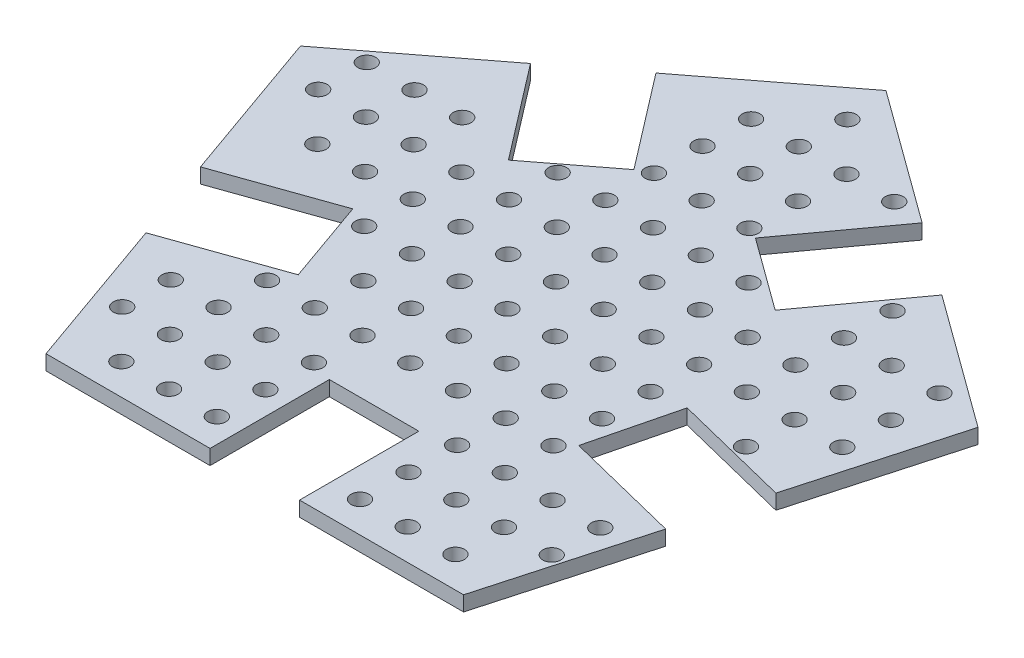
from build123d import *

# Parameters (mm, degrees)
SKETCH1_R           = 3
BOSS_EXTRUDE1_DEPTH = 5


with BuildPart() as part:
    # Sketch1 → Boss-Extrude1 (new body)
    with BuildSketch(Plane(origin=(0, 0, 0), x_dir=(1, 0, 0), z_dir=(0, 1, 0))):
        Polygon((33.8816744, 72.09863232), (-10.595420339, 104.452736288), (-54.231730978, 70.973303889), (-29.88305287, 39.237805242), (-53.684676855, 20.976296661), (-78.033354964, 52.711795308), (-121.669665603, 19.232362909), (-103.331670223, -32.62048586), (-65.620507482, -19.283761946), (-55.617964547, -47.567134002), (-93.329127288, -60.903857915), (-74.991131907, -112.756706684), (-19.991131907, -112.756706684), (-19.991131907, -72.756706684), (10.008868093, -72.756706684), (10.008868093, -112.756706684), (65.008868093, -112.756706684), (79.784278091, -59.778529484), (40.969230286, -50.114572533), (48.214362749, -21.014674397), (87.843592635, -30.881341921), (102.619002633, 22.096835279), (58.141907894, 54.450939247), (34.611650463, 22.103961255), (10.351416969, 39.751654328), align=None)
        with Locations((-105.788667233, 25.573221778)):
            Circle(SKETCH1_R, mode=Mode.SUBTRACT)
        with Locations((-89.788667233, 25.573221778)):
            Circle(SKETCH1_R, mode=Mode.SUBTRACT)
        with Locations((-73.788667233, 25.573221778)):
            Circle(SKETCH1_R, mode=Mode.SUBTRACT)
        with Locations((-41.788667233, 25.573221778)):
            Circle(SKETCH1_R, mode=Mode.SUBTRACT)
        with Locations((-25.788667233, 25.573221778)):
            Circle(SKETCH1_R, mode=Mode.SUBTRACT)
        with Locations((-9.788667233, 25.573221778)):
            Circle(SKETCH1_R, mode=Mode.SUBTRACT)
        with Locations((6.211332767, 25.573221778)):
            Circle(SKETCH1_R, mode=Mode.SUBTRACT)
        with Locations((22.211332767, 25.573221778)):
            Circle(SKETCH1_R, mode=Mode.SUBTRACT)
        with Locations((54.211332767, 25.573221778)):
            Circle(SKETCH1_R, mode=Mode.SUBTRACT)
        with Locations((70.211332767, 25.573221778)):
            Circle(SKETCH1_R, mode=Mode.SUBTRACT)
        with Locations((86.211332767, 25.573221778)):
            Circle(SKETCH1_R, mode=Mode.SUBTRACT)
        with Locations((-106.074287638, 9.575771325)):
            Circle(SKETCH1_R, mode=Mode.SUBTRACT)
        with Locations((-90.074287638, 9.575771325)):
            Circle(SKETCH1_R, mode=Mode.SUBTRACT)
        with Locations((-74.074287638, 9.575771325)):
            Circle(SKETCH1_R, mode=Mode.SUBTRACT)
        with Locations((-58.074287638, 9.575771325)):
            Circle(SKETCH1_R, mode=Mode.SUBTRACT)
        with Locations((-42.074287638, 9.575771325)):
            Circle(SKETCH1_R, mode=Mode.SUBTRACT)
        with Locations((-26.074287638, 9.575771325)):
            Circle(SKETCH1_R, mode=Mode.SUBTRACT)
        with Locations((-10.074287638, 9.575771325)):
            Circle(SKETCH1_R, mode=Mode.SUBTRACT)
        with Locations((5.925712362, 9.575771325)):
            Circle(SKETCH1_R, mode=Mode.SUBTRACT)
        with Locations((21.925712362, 9.575771325)):
            Circle(SKETCH1_R, mode=Mode.SUBTRACT)
        with Locations((37.925712362, 9.575771325)):
            Circle(SKETCH1_R, mode=Mode.SUBTRACT)
        with Locations((53.925712362, 9.575771325)):
            Circle(SKETCH1_R, mode=Mode.SUBTRACT)
        with Locations((69.925712362, 9.575771325)):
            Circle(SKETCH1_R, mode=Mode.SUBTRACT)
        with Locations((85.925712362, 9.575771325)):
            Circle(SKETCH1_R, mode=Mode.SUBTRACT)
        with Locations((-90.359908044, -6.421679127)):
            Circle(SKETCH1_R, mode=Mode.SUBTRACT)
        with Locations((-74.359908044, -6.421679127)):
            Circle(SKETCH1_R, mode=Mode.SUBTRACT)
        with Locations((-58.359908044, -6.421679127)):
            Circle(SKETCH1_R, mode=Mode.SUBTRACT)
        with Locations((-42.359908044, -6.421679127)):
            Circle(SKETCH1_R, mode=Mode.SUBTRACT)
        with Locations((-26.359908044, -6.421679127)):
            Circle(SKETCH1_R, mode=Mode.SUBTRACT)
        with Locations((-10.359908044, -6.421679127)):
            Circle(SKETCH1_R, mode=Mode.SUBTRACT)
        with Locations((5.640091956, -6.421679127)):
            Circle(SKETCH1_R, mode=Mode.SUBTRACT)
        with Locations((21.640091956, -6.421679127)):
            Circle(SKETCH1_R, mode=Mode.SUBTRACT)
        with Locations((37.640091956, -6.421679127)):
            Circle(SKETCH1_R, mode=Mode.SUBTRACT)
        with Locations((53.640091956, -6.421679127)):
            Circle(SKETCH1_R, mode=Mode.SUBTRACT)
        with Locations((69.640091956, -6.421679127)):
            Circle(SKETCH1_R, mode=Mode.SUBTRACT)
        with Locations((85.640091956, -6.421679127)):
            Circle(SKETCH1_R, mode=Mode.SUBTRACT)
        with Locations((-58.645528449, -22.41912958)):
            Circle(SKETCH1_R, mode=Mode.SUBTRACT)
        with Locations((-42.645528449, -22.41912958)):
            Circle(SKETCH1_R, mode=Mode.SUBTRACT)
        with Locations((-26.645528449, -22.41912958)):
            Circle(SKETCH1_R, mode=Mode.SUBTRACT)
        with Locations((-10.645528449, -22.41912958)):
            Circle(SKETCH1_R, mode=Mode.SUBTRACT)
        with Locations((5.354471551, -22.41912958)):
            Circle(SKETCH1_R, mode=Mode.SUBTRACT)
        with Locations((21.354471551, -22.41912958)):
            Circle(SKETCH1_R, mode=Mode.SUBTRACT)
        with Locations((37.354471551, -22.41912958)):
            Circle(SKETCH1_R, mode=Mode.SUBTRACT)
        with Locations((69.354471551, -22.41912958)):
            Circle(SKETCH1_R, mode=Mode.SUBTRACT)
        with Locations((-42.931148854, -38.416580032)):
            Circle(SKETCH1_R, mode=Mode.SUBTRACT)
        with Locations((-26.931148854, -38.416580032)):
            Circle(SKETCH1_R, mode=Mode.SUBTRACT)
        with Locations((-10.931148854, -38.416580032)):
            Circle(SKETCH1_R, mode=Mode.SUBTRACT)
        with Locations((5.068851146, -38.416580032)):
            Circle(SKETCH1_R, mode=Mode.SUBTRACT)
        with Locations((21.068851146, -38.416580032)):
            Circle(SKETCH1_R, mode=Mode.SUBTRACT)
        with Locations((37.068851146, -38.416580032)):
            Circle(SKETCH1_R, mode=Mode.SUBTRACT)
        with Locations((-59.216769259, -54.414030485)):
            Circle(SKETCH1_R, mode=Mode.SUBTRACT)
        with Locations((-43.216769259, -54.414030485)):
            Circle(SKETCH1_R, mode=Mode.SUBTRACT)
        with Locations((-27.216769259, -54.414030485)):
            Circle(SKETCH1_R, mode=Mode.SUBTRACT)
        with Locations((-11.216769259, -54.414030485)):
            Circle(SKETCH1_R, mode=Mode.SUBTRACT)
        with Locations((4.783230741, -54.414030485)):
            Circle(SKETCH1_R, mode=Mode.SUBTRACT)
        with Locations((20.783230741, -54.414030485)):
            Circle(SKETCH1_R, mode=Mode.SUBTRACT)
        with Locations((36.783230741, -54.414030485)):
            Circle(SKETCH1_R, mode=Mode.SUBTRACT)
        with Locations((-75.502389665, -70.411480938)):
            Circle(SKETCH1_R, mode=Mode.SUBTRACT)
        with Locations((-59.502389665, -70.411480938)):
            Circle(SKETCH1_R, mode=Mode.SUBTRACT)
        with Locations((-43.502389665, -70.411480938)):
            Circle(SKETCH1_R, mode=Mode.SUBTRACT)
        with Locations((-27.502389665, -70.411480938)):
            Circle(SKETCH1_R, mode=Mode.SUBTRACT)
        with Locations((20.497610335, -70.411480938)):
            Circle(SKETCH1_R, mode=Mode.SUBTRACT)
        with Locations((36.497610335, -70.411480938)):
            Circle(SKETCH1_R, mode=Mode.SUBTRACT)
        with Locations((52.497610335, -70.411480938)):
            Circle(SKETCH1_R, mode=Mode.SUBTRACT)
        with Locations((68.497610335, -70.411480938)):
            Circle(SKETCH1_R, mode=Mode.SUBTRACT)
        with Locations((-75.78801007, -86.40893139)):
            Circle(SKETCH1_R, mode=Mode.SUBTRACT)
        with Locations((-59.78801007, -86.40893139)):
            Circle(SKETCH1_R, mode=Mode.SUBTRACT)
        with Locations((-43.78801007, -86.40893139)):
            Circle(SKETCH1_R, mode=Mode.SUBTRACT)
        with Locations((-27.78801007, -86.40893139)):
            Circle(SKETCH1_R, mode=Mode.SUBTRACT)
        with Locations((20.21198993, -86.40893139)):
            Circle(SKETCH1_R, mode=Mode.SUBTRACT)
        with Locations((36.21198993, -86.40893139)):
            Circle(SKETCH1_R, mode=Mode.SUBTRACT)
        with Locations((52.21198993, -86.40893139)):
            Circle(SKETCH1_R, mode=Mode.SUBTRACT)
        with Locations((68.21198993, -86.40893139)):
            Circle(SKETCH1_R, mode=Mode.SUBTRACT)
        with Locations((-60.073630475, -102.406381843)):
            Circle(SKETCH1_R, mode=Mode.SUBTRACT)
        with Locations((-44.073630475, -102.406381843)):
            Circle(SKETCH1_R, mode=Mode.SUBTRACT)
        with Locations((-28.073630475, -102.406381843)):
            Circle(SKETCH1_R, mode=Mode.SUBTRACT)
        with Locations((19.926369525, -102.406381843)):
            Circle(SKETCH1_R, mode=Mode.SUBTRACT)
        with Locations((35.926369525, -102.406381843)):
            Circle(SKETCH1_R, mode=Mode.SUBTRACT)
        with Locations((51.926369525, -102.406381843)):
            Circle(SKETCH1_R, mode=Mode.SUBTRACT)
        with Locations((-25.217426422, 57.568122683)):
            Circle(SKETCH1_R, mode=Mode.SUBTRACT)
        with Locations((-9.217426422, 57.568122683)):
            Circle(SKETCH1_R, mode=Mode.SUBTRACT)
        with Locations((6.782573578, 57.568122683)):
            Circle(SKETCH1_R, mode=Mode.SUBTRACT)
        with Locations((-24.931806017, 73.565573136)):
            Circle(SKETCH1_R, mode=Mode.SUBTRACT)
        with Locations((-8.931806017, 73.565573136)):
            Circle(SKETCH1_R, mode=Mode.SUBTRACT)
        with Locations((7.068193983, 73.565573136)):
            Circle(SKETCH1_R, mode=Mode.SUBTRACT)
        with Locations((23.068193983, 73.565573136)):
            Circle(SKETCH1_R, mode=Mode.SUBTRACT)
        with Locations((-8.646185612, 89.563023589)):
            Circle(SKETCH1_R, mode=Mode.SUBTRACT)
        with Locations((54.496953172, 41.570672231)):
            Circle(SKETCH1_R, mode=Mode.SUBTRACT)
        with Locations((6.496953172, 41.570672231)):
            Circle(SKETCH1_R, mode=Mode.SUBTRACT)
        with Locations((-9.503046828, 41.570672231)):
            Circle(SKETCH1_R, mode=Mode.SUBTRACT)
        with Locations((-25.503046828, 41.570672231)):
            Circle(SKETCH1_R, mode=Mode.SUBTRACT)
    extrude(amount=BOSS_EXTRUDE1_DEPTH)


solid = part.part
